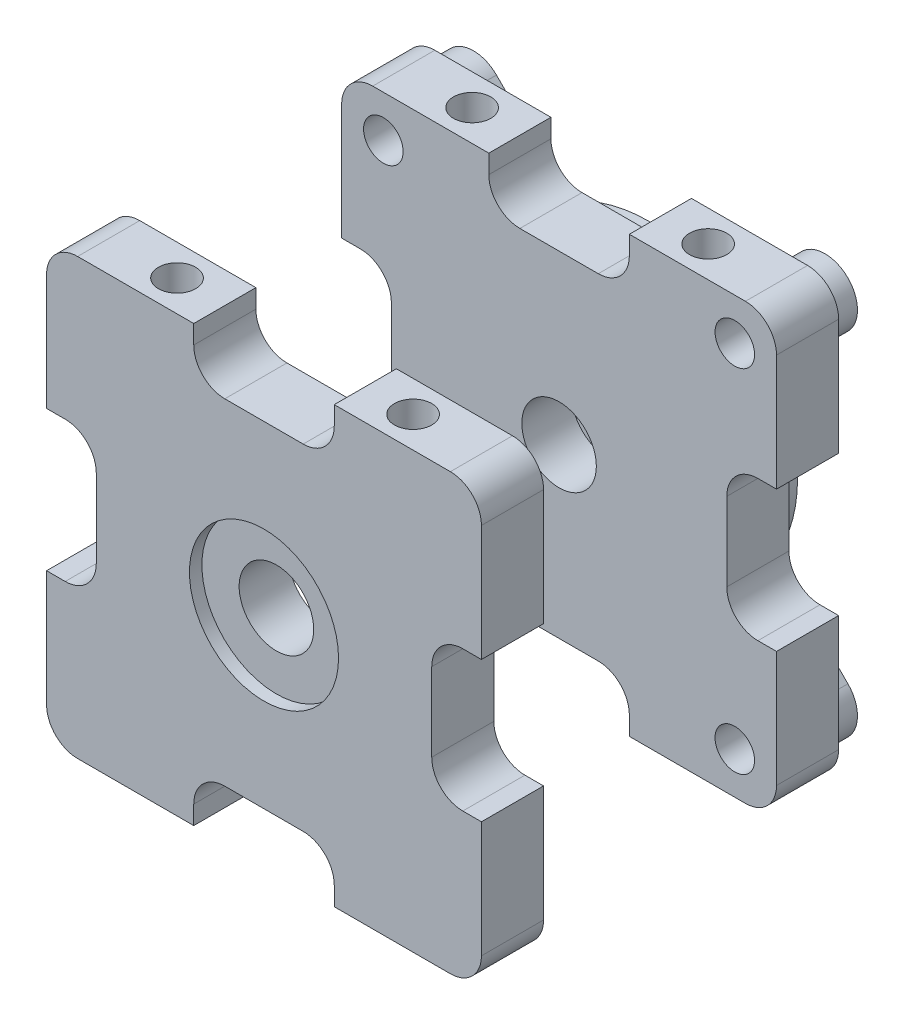
from build123d import *

# Parameters (mm, degrees)
BOSS_EXTRUDE1_DEPTH = 10
SKETCH2_R           = 3
CUT_EXTRUDE1_DEPTH  = 71
SKETCH3_R           = 12
CUT_EXTRUDE2_DEPTH  = 2
SKETCH4_R           = 6
CUT_EXTRUDE3_DEPTH  = 9
BOSS_EXTRUDE2_DEPTH = 4.5
SKETCH6_R           = 3.181997279
SKETCH6_R_2         = 6
CUT_EXTRUDE4_DEPTH  = 14.5


with BuildPart() as part:
    # Sketch1 → Boss-Extrude1 (new body)
    with BuildSketch(Plane.XY):
        with BuildLine():
            Line((-30, 35), (-11.308829268, 35))
            Line((-11.308829268, 35), (-11.308829268, 32))
            ThreePointArc((-11.308829268, 32), (-9.844363174, 28.464466094), (-6.308829268, 27))
            Line((-6.308829268, 27), (6.308829268, 27))
            ThreePointArc((6.308829268, 27), (9.844363174, 28.464466094), (11.308829268, 32))
            Line((11.308829268, 32), (11.308829268, 35))
            Line((11.308829268, 35), (30, 35))
            ThreePointArc((30, 35), (33.535533906, 33.535533906), (35, 30))
            Line((35, 30), (35, 11.310607042))
            Line((35, 11.310607042), (32, 11.310607042))
            ThreePointArc((32, 11.310607042), (28.464466094, 9.846140948), (27, 6.310607042))
            Line((27, 6.310607042), (27, -6.310607042))
            ThreePointArc((27, -6.310607042), (28.464466094, -9.846140948), (32, -11.310607042))
            Line((32, -11.310607042), (35, -11.310607042))
            Line((35, -11.310607042), (35, -30))
            ThreePointArc((35, -30), (33.535533906, -33.535533906), (30, -35))
            Line((30, -35), (11.31, -35))
            Line((11.31, -35), (11.31, -32))
            ThreePointArc((11.31, -32), (9.845533906, -28.464466094), (6.31, -27))
            Line((6.31, -27), (-6.31, -27))
            ThreePointArc((-6.31, -27), (-9.845533906, -28.464466094), (-11.31, -32))
            Line((-11.31, -32), (-11.31, -35))
            Line((-11.31, -35), (-30, -35))
            ThreePointArc((-30, -35), (-33.535533906, -33.535533906), (-35, -30))
            Line((-35, -30), (-35, -11.308825459))
            Line((-35, -11.308825459), (-32, -11.308825459))
            ThreePointArc((-32, -11.308825459), (-28.464466094, -9.844359365), (-27, -6.308825459))
            Line((-27, -6.308825459), (-27, 6.308825459))
            ThreePointArc((-27, 6.308825459), (-28.464466094, 9.844359365), (-32, 11.308825459))
            Line((-32, 11.308825459), (-35, 11.308825459))
            Line((-35, 11.308825459), (-35, 30))
            ThreePointArc((-35, 30), (-33.535533906, 33.535533906), (-30, 35))
        make_face()
    extrude(amount=BOSS_EXTRUDE1_DEPTH)

    # Sketch2 → Cut-Extrude1 (cut, through all)
    with BuildSketch(Plane(origin=(0, 35, 0), x_dir=(1, 0, 0), z_dir=(0, 1, 0))):
        with Locations((-19, -5)):
            Circle(SKETCH2_R)
        with Locations((19, -5)):
            Circle(SKETCH2_R)
    extrude(amount=-CUT_EXTRUDE1_DEPTH, mode=Mode.SUBTRACT)

    # Sketch3 → Cut-Extrude2 (cut)
    with BuildSketch(Plane.XY.offset(10)):
        Circle(SKETCH3_R)
    extrude(amount=-CUT_EXTRUDE2_DEPTH, mode=Mode.SUBTRACT)

    # Sketch4 → Cut-Extrude3 (cut, through all)
    with BuildSketch(Plane.XY.offset(8)):
        Circle(SKETCH4_R)
    extrude(amount=-CUT_EXTRUDE3_DEPTH, mode=Mode.SUBTRACT)


with BuildPart() as body_2:
    # Mirror12: mirrored copy
    add(part.part.mirror(Plane(origin=(0, 0, -18.75), x_dir=(1, 0, 0), z_dir=(0, 0, -1))))

    # Sketch5 → Boss-Extrude2 (add)
    with BuildSketch(Plane(origin=(0, 0, -47.5), x_dir=(-1, 0, 0), z_dir=(0, 0, -1))):
        with BuildLine():
            Line((-24.577345561, 31.998551775), (-15.319573038, 22.740779251))
            ThreePointArc((-15.319573038, 22.740779251), (-12.751569301, 21.395635962), (-9.874588176, 21.75205323))
            ThreePointArc((-9.874588176, 21.75205323), (0, 23.888476539), (9.874588176, 21.75205323))
            ThreePointArc((9.874588176, 21.75205323), (12.751569301, 21.395635962), (15.319573038, 22.740779251))
            Line((15.319573038, 22.740779251), (24.577345561, 31.998551775))
            ThreePointArc((24.577345561, 31.998551775), (31.998551775, 31.998551775), (31.998551775, 24.577345561))
            Line((31.998551775, 24.577345561), (22.740779251, 15.319573038))
            ThreePointArc((22.740779251, 15.319573038), (21.395635962, 12.751569301), (21.75205323, 9.874588176))
            ThreePointArc((21.75205323, 9.874588176), (23.888476539, 0), (21.75205323, -9.874588176))
            ThreePointArc((21.75205323, -9.874588176), (21.395635962, -12.751569301), (22.740779251, -15.319573038))
            Line((22.740779251, -15.319573038), (31.998551775, -24.577345561))
            ThreePointArc((31.998551775, -24.577345561), (31.998551775, -31.998551775), (24.577345561, -31.998551775))
            Line((24.577345561, -31.998551775), (15.319573038, -22.740779251))
            ThreePointArc((15.319573038, -22.740779251), (12.751569301, -21.395635962), (9.874588176, -21.75205323))
            ThreePointArc((9.874588176, -21.75205323), (0, -23.888476539), (-9.874588176, -21.75205323))
            ThreePointArc((-9.874588176, -21.75205323), (-12.751569301, -21.395635962), (-15.319573038, -22.740779251))
            Line((-15.319573038, -22.740779251), (-24.577345561, -31.998551775))
            ThreePointArc((-24.577345561, -31.998551775), (-31.998551775, -31.998551775), (-31.998551775, -24.577345561))
            Line((-31.998551775, -24.577345561), (-22.740779251, -15.319573038))
            ThreePointArc((-22.740779251, -15.319573038), (-21.395635962, -12.751569301), (-21.75205323, -9.874588176))
            ThreePointArc((-21.75205323, -9.874588176), (-23.888476539, 0), (-21.75205323, 9.874588176))
            ThreePointArc((-21.75205323, 9.874588176), (-21.395635962, 12.751569301), (-22.740779251, 15.319573038))
            Line((-22.740779251, 15.319573038), (-31.998551775, 24.577345561))
            ThreePointArc((-31.998551775, 24.577345561), (-31.998551775, 31.998551775), (-24.577345561, 31.998551775))
        make_face()
    extrude(amount=BOSS_EXTRUDE2_DEPTH)

    # Sketch6 → Cut-Extrude4 (cut)
    with BuildSketch(Plane(origin=(0, 0, -52), x_dir=(-1, 0, 0), z_dir=(0, 0, -1))):
        with Locations((-28.287948668, 28.287948668)):
            Circle(SKETCH6_R)
        with Locations((28.287948668, 28.287948668)):
            Circle(SKETCH6_R)
        with Locations((28.287948668, -28.287948668)):
            Circle(SKETCH6_R)
        with Locations((-28.287948668, -28.287948668)):
            Circle(SKETCH6_R)
        Circle(SKETCH6_R_2)
    extrude(amount=-CUT_EXTRUDE4_DEPTH, mode=Mode.SUBTRACT)


solid = Compound([part.part, body_2.part])
